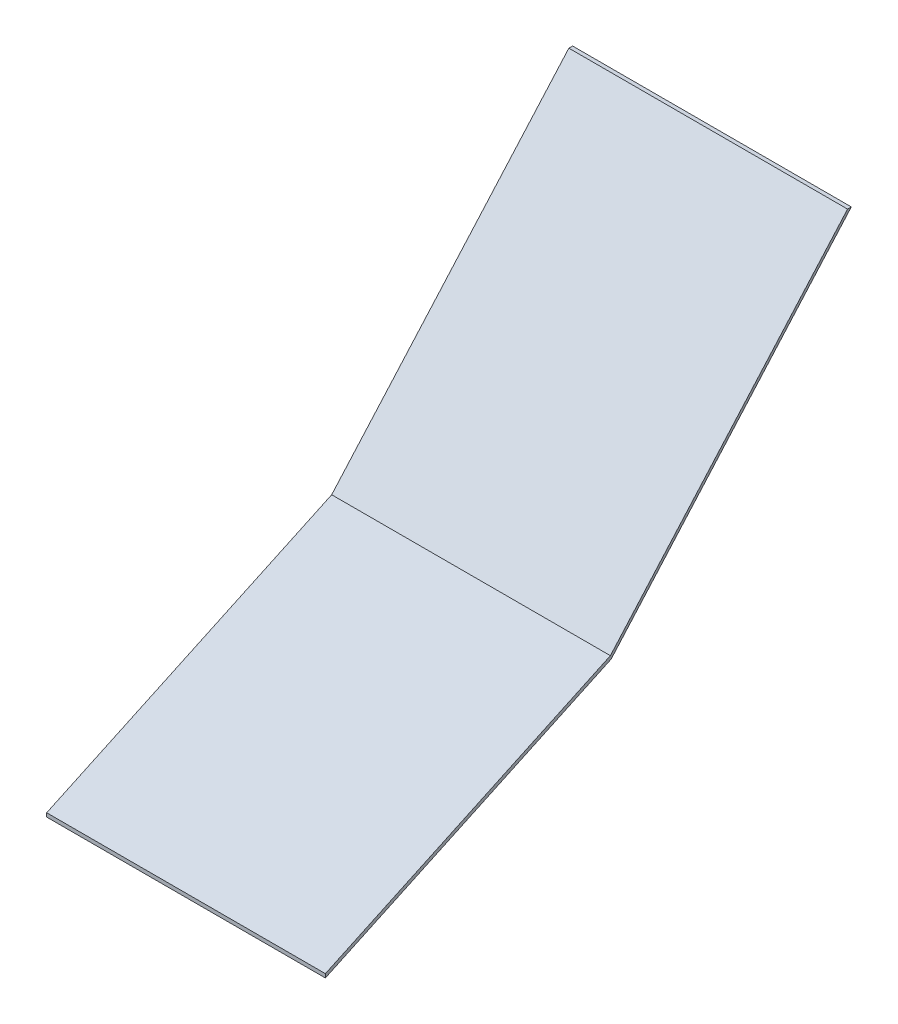
from build123d import *

# Parameters (mm, degrees)
BOSS_EXTRUDE1_DEPTH = 112.268


with BuildPart() as part:
    # Sketch1 → Boss-Extrude1 (new body)
    with BuildSketch(Plane(origin=(0, 0, 0), x_dir=(0, 0, -1), z_dir=(1, 0, 0))):
        Polygon((0, 0), (114.802300061, 53.533191692), (210.338734241, 161.555471135), (211.857654241, 161.555471135), (115.101088954, 52.153599241), (0, -1.51892), align=None)
    extrude(amount=BOSS_EXTRUDE1_DEPTH)


solid = part.part
